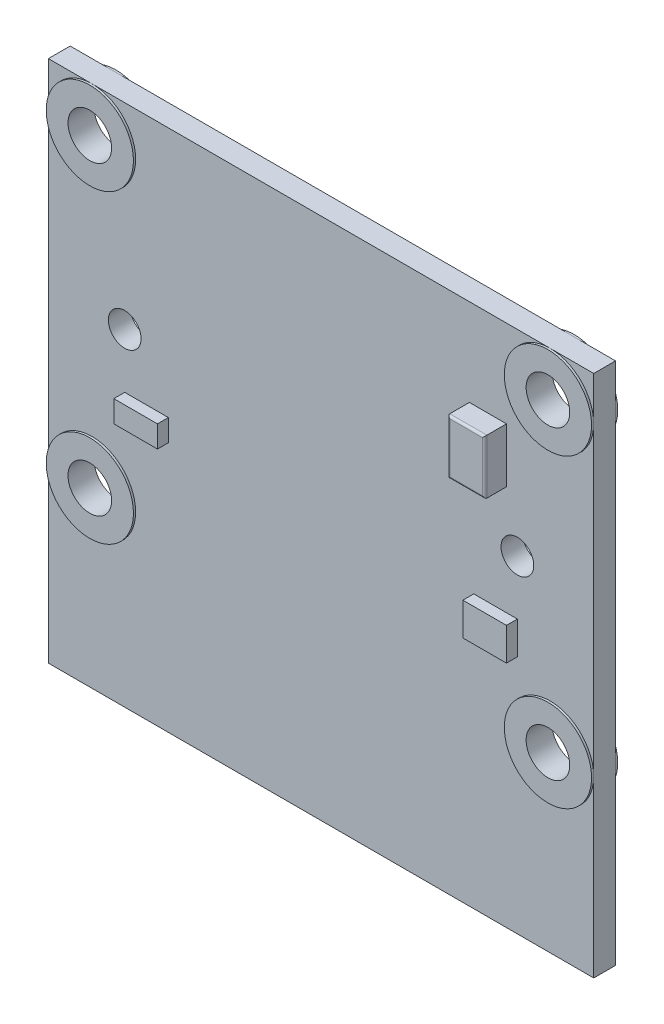
from build123d import *

# Parameters (mm, degrees)
SKETCH1_W                = 25
SKETCH1_H                = 24
BOSS_EXTRUDE1_DEPTH      = 1
SKETCH2_R                = 1
SKETCH2_R_2              = 0.75
CUT_EXTRUDE1_DEPTH       = 2
SKETCH3_R                = 2
SKETCH3_R_2              = 1
BOSS_EXTRUDE3_DEPTH      = 0.1
BOSS_EXTRUDE3_DEPTH_BACK = 1.1
SKETCH4_W                = 1.7
SKETCH4_H                = 2.5
BOSS_EXTRUDE4_DEPTH      = 1
FILLET1_R                = 0.1
SKETCH5_W                = 2
SKETCH5_H                = 1
SKETCH5_H_2              = 1.5
BOSS_EXTRUDE5_DEPTH      = 0.5


with BuildPart() as part:
    # Sketch1 → Boss-Extrude1 (new body)
    with BuildSketch(Plane.XY):
        Rectangle(SKETCH1_W, SKETCH1_H)
    extrude(amount=BOSS_EXTRUDE1_DEPTH)

    # Sketch2 → Cut-Extrude1 (cut)
    with BuildSketch(Plane.XY.offset(1)):
        with Locations((-10.5, 10)):
            Circle(SKETCH2_R)
        with Locations((10.5, 10)):
            Circle(SKETCH2_R)
        with Locations((10.5, -4)):
            Circle(SKETCH2_R)
        with Locations((-10.5, -4)):
            Circle(SKETCH2_R)
        with Locations((-9, 3)):
            Circle(SKETCH2_R_2)
        with Locations((9, 3)):
            Circle(SKETCH2_R_2)
    extrude(amount=-CUT_EXTRUDE1_DEPTH, mode=Mode.SUBTRACT)

    # Sketch3 → Boss-Extrude3 (add, two sides)
    with BuildSketch(Plane.XY.offset(1)) as boss_extrude3_sk:
        with Locations((-10.5, 10)):
            Circle(SKETCH3_R)
        with Locations((-10.5, 10)):
            Circle(SKETCH3_R_2, mode=Mode.SUBTRACT)
        with Locations((10.5, 10)):
            Circle(SKETCH3_R)
        with Locations((10.5, 10)):
            Circle(SKETCH3_R_2, mode=Mode.SUBTRACT)
        with Locations((10.5, -4)):
            Circle(SKETCH3_R)
        with Locations((10.5, -4)):
            Circle(SKETCH3_R_2, mode=Mode.SUBTRACT)
        with Locations((-10.5, -4)):
            Circle(SKETCH3_R)
        with Locations((-10.5, -4)):
            Circle(SKETCH3_R_2, mode=Mode.SUBTRACT)
    extrude(amount=BOSS_EXTRUDE3_DEPTH)
    extrude(boss_extrude3_sk.sketch, amount=-BOSS_EXTRUDE3_DEPTH_BACK)

    # Sketch4 → Boss-Extrude4 (add)
    with BuildSketch(Plane.XY.offset(1)):
        with Locations((7.65, 6.75)):
            Rectangle(SKETCH4_W, SKETCH4_H)
    extrude(amount=BOSS_EXTRUDE4_DEPTH)

    # Fillet1
    fillet1_edges = [part.edges().sort_by_distance(p)[0] for p in [
        (8.5, 6.75, 2),
        (7.65, 8, 2),
        (6.8, 6.75, 2),
        (7.65, 5.5, 2),
    ]]
    fillet(fillet1_edges, radius=FILLET1_R)

    # Sketch5 → Boss-Extrude5 (add)
    with BuildSketch(Plane.XY.offset(1)):
        with Locations((-8, 0)):
            Rectangle(SKETCH5_W, SKETCH5_H)
        with Locations((8, -0.25)):
            Rectangle(SKETCH5_W, SKETCH5_H_2)
    extrude(amount=BOSS_EXTRUDE5_DEPTH)


solid = part.part
